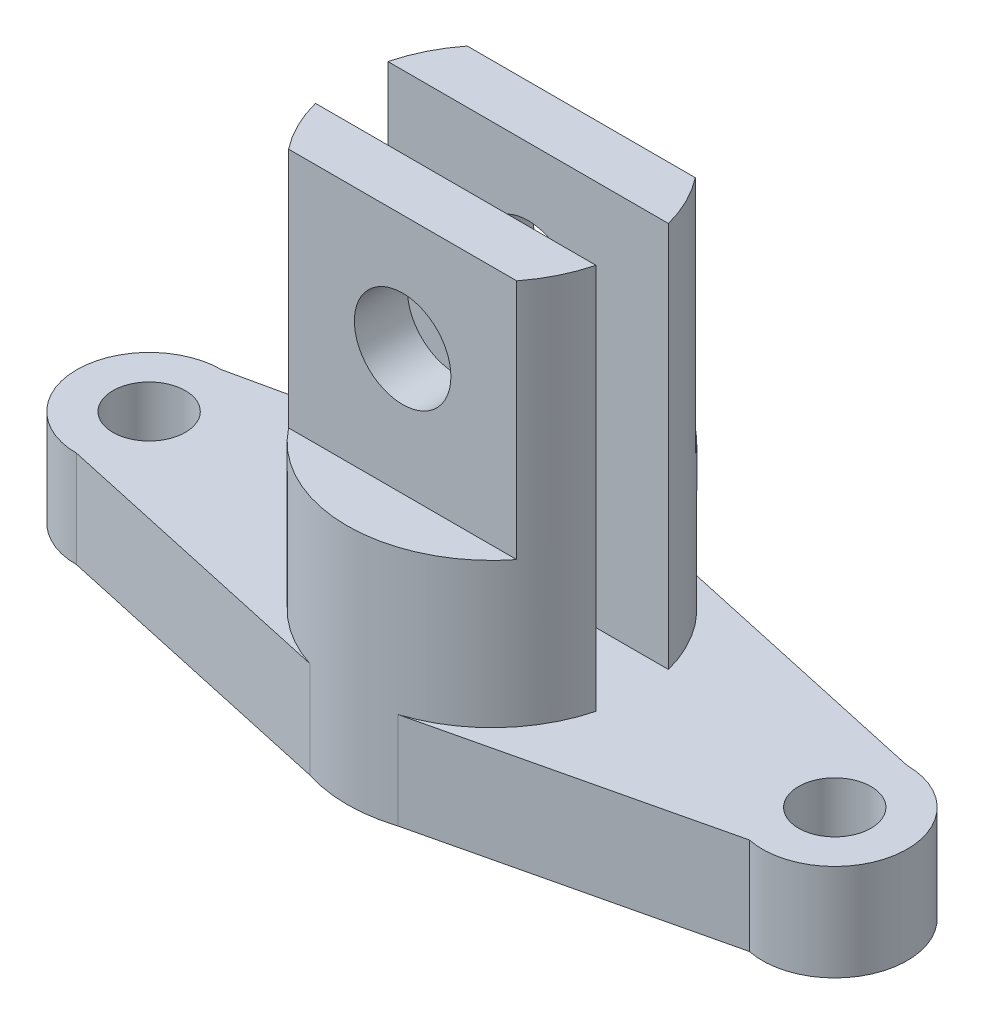
from build123d import *

# Parameters (mm, degrees)
SKETCH1_R               = 7.5
BOSS_EXTRUDE1_DEPTH     = 20
BOSS_EXTRUDE2_DEPTH     = 100
CUT_EXTRUDE1_DEPTH      = 50
SKETCH4_R               = 10
CUT_EXTRUDE2_DEPTH      = 30
CUT_EXTRUDE2_DEPTH_BACK = 119


with BuildPart() as part:
    # Sketch1 → Boss-Extrude1 (new body)
    with BuildSketch(Plane(origin=(0, 0, 0), x_dir=(1, 0, 0), z_dir=(0, 1, 0))):
        with BuildLine():
            Line((-49.860018769, -23.434965581), (11.985981198, -37.004254746))
            ThreePointArc((11.985981198, -37.004254746), (21.139981231, -38.434965581), (30.293981265, -37.004254746))
            Line((30.293981265, -37.004254746), (89.131173769, -23.130103473))
            ThreePointArc((89.131173769, -23.130103473), (107.063571087, -9.947071997), (92.139981231, 6.565034419))
            Line((92.139981231, 6.565034419), (30.293981265, 20.134323584))
            ThreePointArc((30.293981265, 20.134323584), (21.139981231, 21.565034419), (11.985981198, 20.134323584))
            Line((11.985981198, 20.134323584), (-49.860018769, 6.565034419))
            ThreePointArc((-49.860018769, 6.565034419), (-64.860018769, -8.434965581), (-49.860018769, -23.434965581))
        make_face()
        with Locations((-49.860018769, -8.434965581)):
            Circle(SKETCH1_R, mode=Mode.SUBTRACT)
        with Locations((92.139981231, -8.434965581)):
            Circle(SKETCH1_R, mode=Mode.SUBTRACT)
    extrude(amount=BOSS_EXTRUDE1_DEPTH)

    # Sketch2 → Boss-Extrude2 (add)
    with BuildSketch(Plane(origin=(0, 0, 0), x_dir=(1, 0, 0), z_dir=(0, 1, 0))):
        with BuildLine():
            Line((-7.907393865, -0.934965581), (50.187356328, -0.934965581))
            ThreePointArc((50.187356328, -0.934965581), (21.139981231, 21.565034419), (-7.907393865, -0.934965581))
        make_face()
        with BuildLine():
            Line((50.187356328, -15.934965581), (-7.907393865, -15.934965581))
            ThreePointArc((-7.907393865, -15.934965581), (21.139981231, -38.434965581), (50.187356328, -15.934965581))
        make_face()
    extrude(amount=BOSS_EXTRUDE2_DEPTH)

    # Sketch3 → Cut-Extrude1 (cut)
    with BuildSketch(Plane(origin=(0, 100, 0), x_dir=(1, 0, 0), z_dir=(0, 1, 0))):
        with BuildLine():
            Line((-2.476750126, -26.934965581), (44.756712589, -26.934965581))
            ThreePointArc((44.756712589, -26.934965581), (21.139981231, -38.434965581), (-2.476750126, -26.934965581))
        make_face()
        with BuildLine():
            Line((44.756712589, 10.065034419), (-2.476750126, 10.065034419))
            ThreePointArc((-2.476750126, 10.065034419), (21.139981231, 21.565034419), (44.756712589, 10.065034419))
        make_face()
    extrude(amount=-CUT_EXTRUDE1_DEPTH, mode=Mode.SUBTRACT)

    # Sketch4 → Cut-Extrude2 (cut, two sides)
    with BuildSketch(Plane.XY.offset(26.934965581)) as cut_extrude2_sk:
        with Locations((21.139981231, 76)):
            Circle(SKETCH4_R)
    extrude(amount=CUT_EXTRUDE2_DEPTH, mode=Mode.SUBTRACT)
    extrude(cut_extrude2_sk.sketch, amount=-CUT_EXTRUDE2_DEPTH_BACK, mode=Mode.SUBTRACT)


solid = part.part
